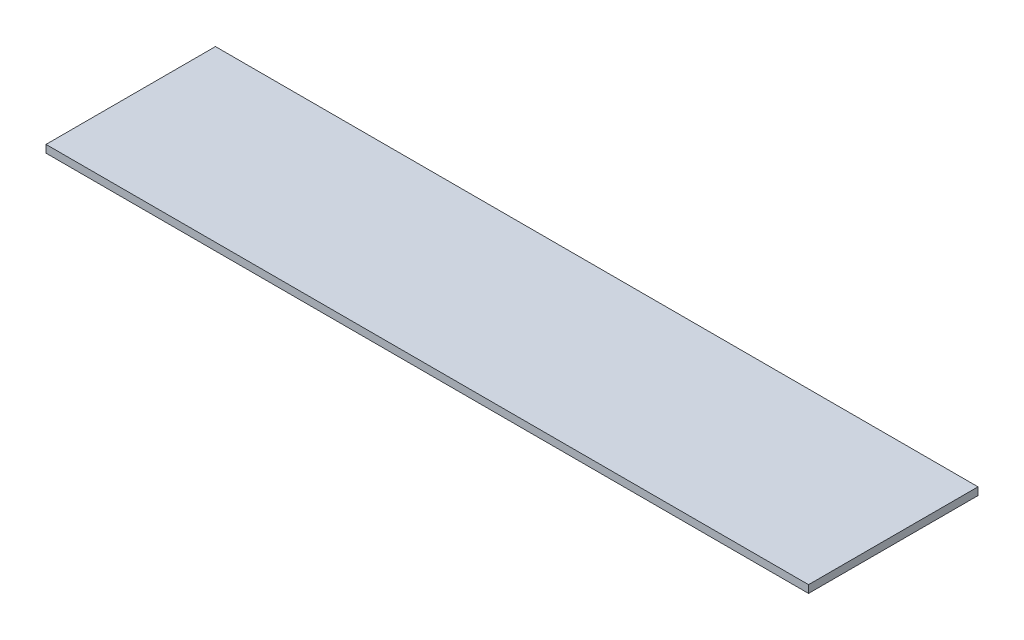
from build123d import *

# Parameters (mm, degrees)
SKETCH_1_W      = 45
SKETCH_1_H      = 10
EXTRUDE_1_DEPTH = 0.45


with BuildPart() as part:
    # 草图1 → 凸台-拉伸1 (new body)
    with BuildSketch(Plane(origin=(0, 0, 0), x_dir=(1, 0, 0), z_dir=(0, 1, 0))):
        with Locations((22.5, 5)):
            Rectangle(SKETCH_1_W, SKETCH_1_H)
    extrude(amount=EXTRUDE_1_DEPTH)


solid = part.part
